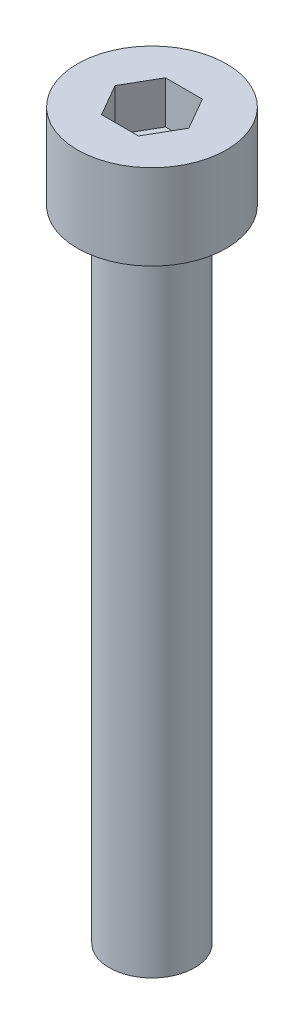
from build123d import *

# Parameters (mm, degrees)
SKETCH_1_R            = 3.5
EXTRUDE_246_DEPTH     = 4
CUT_EXTRUDE_376_DEPTH = 2
SKETCH_3_R            = 2
EXTRUDE_477_DEPTH     = 30


with BuildPart() as part:
    # 草图1 → Extrude 246 (new body)
    with BuildSketch(Plane(origin=(0, 0, 0), x_dir=(1, 0, 0), z_dir=(0, 1, 0))):
        Circle(SKETCH_1_R)
    extrude(amount=EXTRUDE_246_DEPTH)

    # 草图2 → Cut-Extrude 376 (cut)
    with BuildSketch(Plane(origin=(0, 4, 0), x_dir=(1, 0, 0), z_dir=(0, 1, 0))):
        Polygon((1.732050808, 0), (0.866025404, 1.5), (-0.866025404, 1.5), (-1.732050808, 0), (-0.866025404, -1.5), (0.866025404, -1.5), align=None)
    extrude(amount=-CUT_EXTRUDE_376_DEPTH, mode=Mode.SUBTRACT)

    # 草图3 → Extrude 477 (add)
    with BuildSketch(Plane.XZ):
        Circle(SKETCH_3_R)
    extrude(amount=EXTRUDE_477_DEPTH)


solid = part.part
